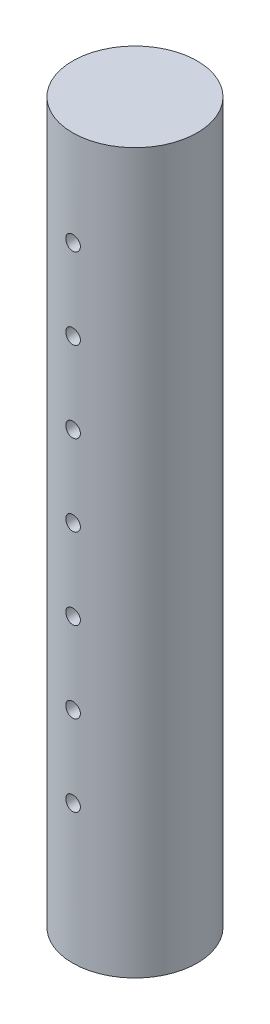
from build123d import *

# Parameters (mm, degrees)
SKETCH1_R           = 3.850000047
BOSS_EXTRUDE1_DEPTH = 44.45
SKETCH4_R           = 0.45
CUT_EXTRUDE1_DEPTH  = 10.16
LPATTERN1_COUNT     = 7
LPATTERN1_PITCH     = 5


with BuildPart() as part:
    # Sketch1 → Boss-Extrude1 (new body)
    with BuildSketch(Plane(origin=(0, 0, 0), x_dir=(1, 0, 0), z_dir=(0, 1, 0))):
        Circle(SKETCH1_R)
    extrude(amount=BOSS_EXTRUDE1_DEPTH)

    # Sketch4 → Cut-Extrude1 (cut)
    with BuildSketch(Plane.XY.offset(5.08)):
        with Locations((0, 8.566631878)):
            Circle(SKETCH4_R)
    cut_extrude1 = extrude(amount=-CUT_EXTRUDE1_DEPTH, mode=Mode.SUBTRACT)

    # LPattern1: Cut-Extrude1 ×7
    with Locations(*[(0, i * LPATTERN1_PITCH, 0) for i in range(1, LPATTERN1_COUNT)]):
        add(cut_extrude1, mode=Mode.SUBTRACT)


solid = part.part
